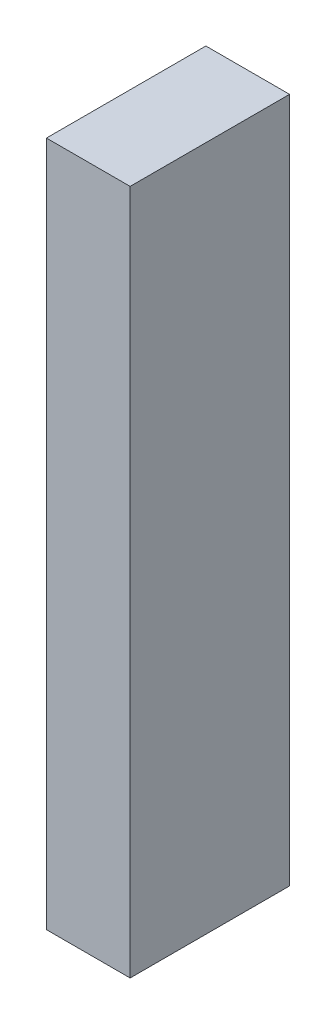
from build123d import *

# Parameters (mm, degrees)
SKETCH1_W           = 40
SKETCH1_H           = 172
BOSS_EXTRUDE1_DEPTH = 21


with BuildPart() as part:
    # Sketch1 → Boss-Extrude1 (new body)
    with BuildSketch(Plane(origin=(0, 0, 0), x_dir=(0, 0, -1), z_dir=(1, 0, 0))):
        Rectangle(SKETCH1_W, SKETCH1_H)
    extrude(amount=BOSS_EXTRUDE1_DEPTH)


solid = part.part
